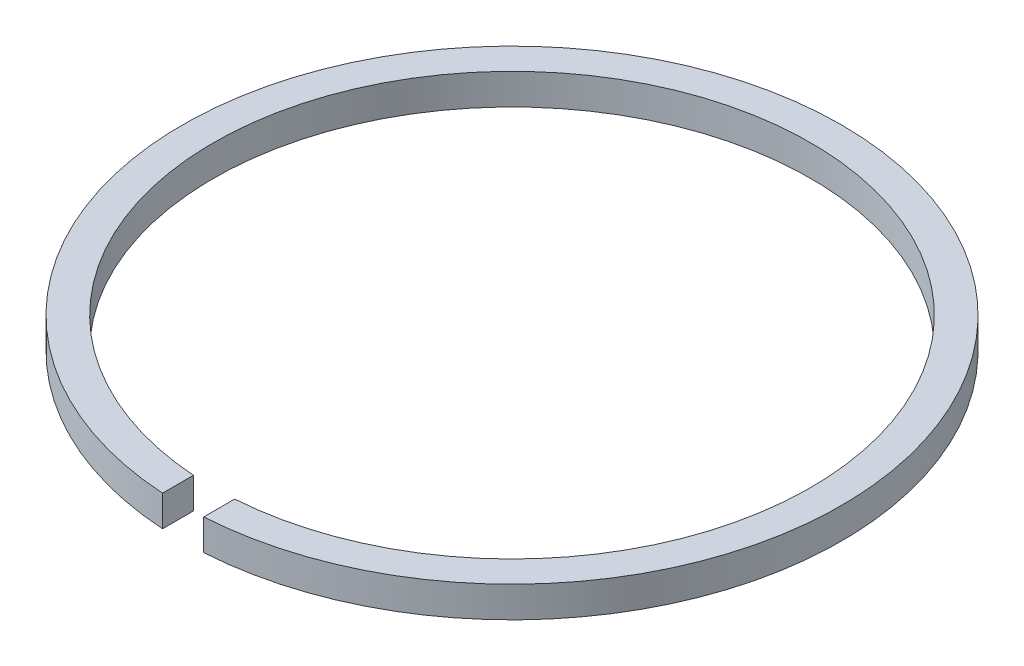
from build123d import *

# Parameters (mm, degrees)
BOSS_EXTRUDE1_DEPTH = 0.75


with BuildPart() as part:
    # Sketch2 → Boss-Extrude1 (new body, symmetric)
    with BuildSketch(Plane(origin=(0, 0, 0), x_dir=(1, 0, 0), z_dir=(0, 1, 0))):
        with BuildLine():
            Line((-1, -15.968719423), (-1, -14.465476141))
            ThreePointArc((-1, -14.465476141), (0, 14.5), (1, -14.465476141))
            Line((1, -14.465476141), (1, -15.968719423))
            ThreePointArc((1, -15.968719423), (0, 16), (-1, -15.968719423))
        make_face()
    extrude(amount=BOSS_EXTRUDE1_DEPTH, both=True)


solid = part.part
